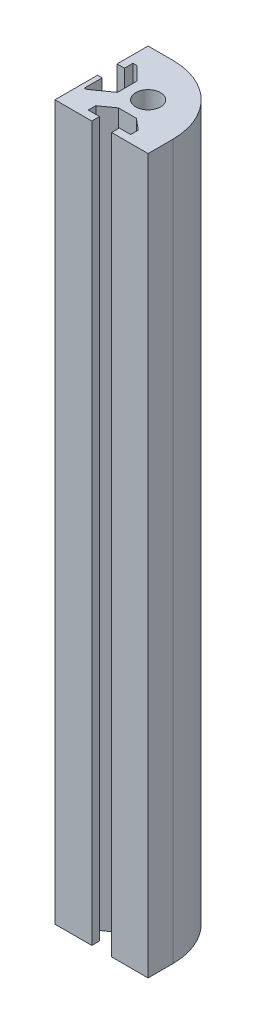
from build123d import *

# Parameters (mm, degrees)
CROQUIS1_R              = 4
SALIENTE_EXTRUIR1_DEPTH = 230


with BuildPart() as part:
    # Croquis1 → Saliente-Extruir1 (new body)
    with BuildSketch(Plane(origin=(0, 0, 0), x_dir=(1, 0, 0), z_dir=(0, 1, 0))):
        with BuildLine():
            Line((-7, 15), (-15, 15))
            Line((-15, 15), (-15, 5.027604917))
            Line((-15, 5.027604917), (-12.623437069, 5.027604917))
            Line((-12.623437069, 5.027604917), (-12.623437069, 7.752682341))
            Line((-12.623437069, 7.752682341), (-11.320548438, 7.752682341))
            Line((-11.320548438, 7.752682341), (-7, 3.432133903))
            Line((-7, 3.432133903), (-7, -2.861090311))
            Line((-7, -2.861090311), (-12.793007796, -7))
            Line((-12.793007796, -7), (-13.527286117, -7))
            Line((-13.527286117, -7), (-13.527286117, -1.25796789))
            Line((-13.527286117, -1.25796789), (-15, -1.25796789))
            Line((-15, -1.25796789), (-15, -15))
            Line((-15, -15), (-3.139941254, -15))
            Line((-3.139941254, -15), (-3.139941254, -12.505835019))
            Line((-3.139941254, -12.505835019), (-6.77895709, -12.505835019))
            Line((-6.77895709, -12.505835019), (-6.77895709, -10.079824462))
            Line((-6.77895709, -10.079824462), (-2.512909638, -7.031876702))
            Line((-2.512909638, -7.031876702), (3.25590476, -7.031876702))
            Line((3.25590476, -7.031876702), (6.894920596, -10.079824462))
            Line((6.894920596, -10.079824462), (6.894920596, -12.505835019))
            Line((6.894920596, -12.505835019), (3.25590476, -12.505835019))
            Line((3.25590476, -12.505835019), (3.25590476, -15))
            Line((3.25590476, -15), (15, -15))
            Line((15, -15), (15, -7))
            ThreePointArc((15, -7), (8.556349186, 8.556349186), (-7, 15))
        make_face()
        Circle(CROQUIS1_R, mode=Mode.SUBTRACT)
    extrude(amount=SALIENTE_EXTRUIR1_DEPTH)


solid = part.part
